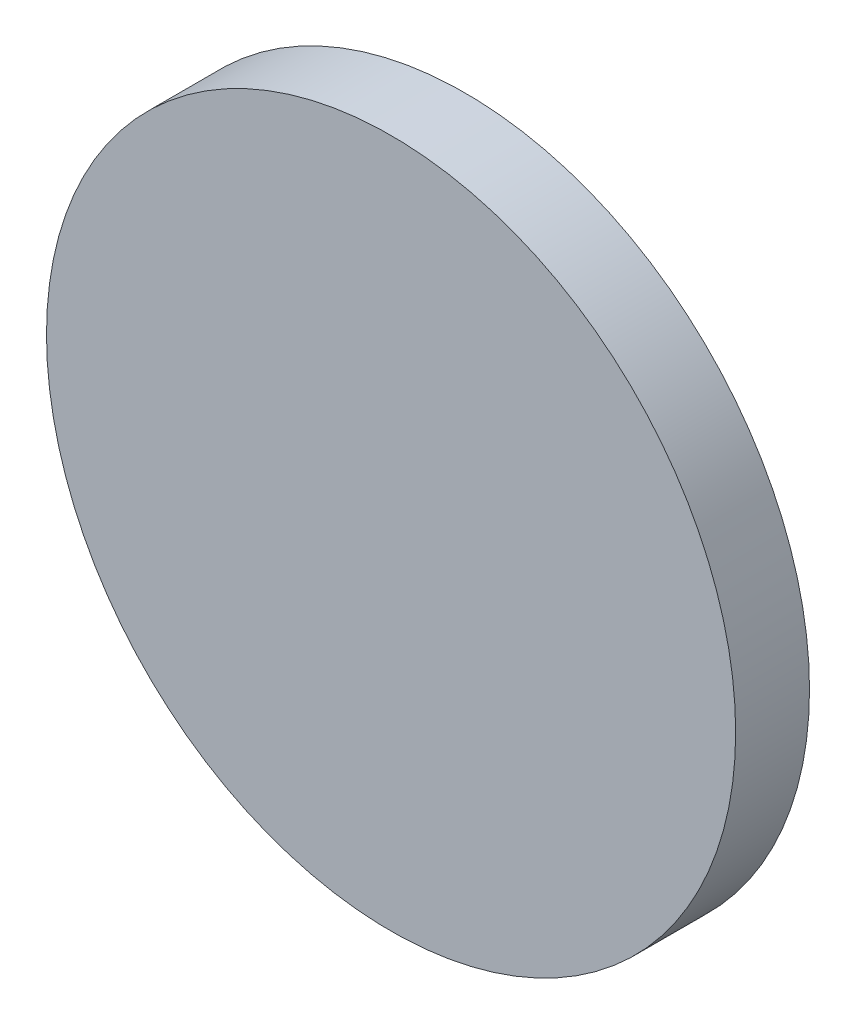
from build123d import *

# Parameters (mm, degrees)
SKETCH1_R           = 14
BOSS_EXTRUDE1_DEPTH = 3


with BuildPart() as part:
    # Sketch1 → Boss-Extrude1 (new body)
    with BuildSketch(Plane.XY):
        Circle(SKETCH1_R)
    extrude(amount=BOSS_EXTRUDE1_DEPTH)


solid = part.part
